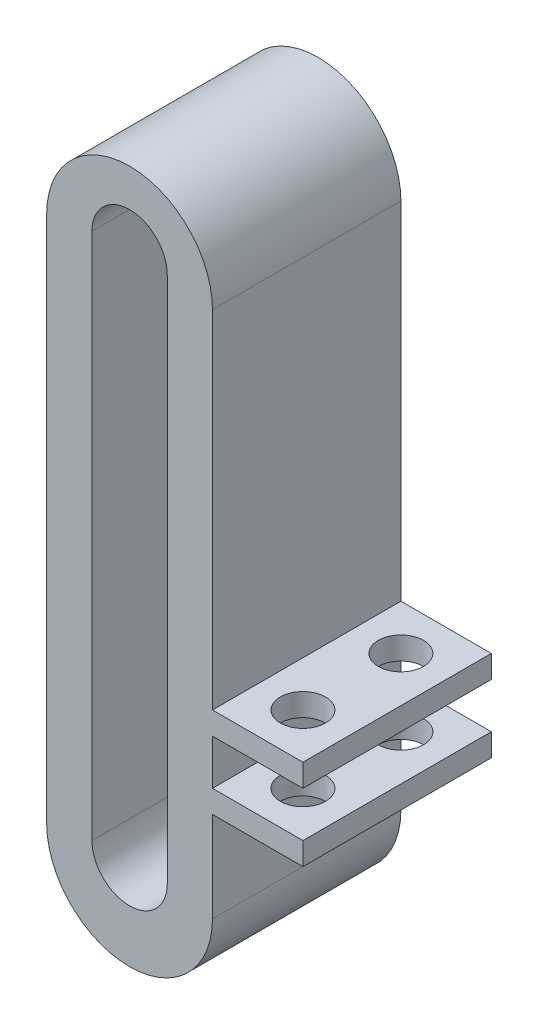
from build123d import *

# Parameters (mm, degrees)
BOSS_EXTRUDE1_DEPTH     = 12.5
SKETCH2_W               = 12.5
SKETCH2_H               = 1.5
BOSS_EXTRUDE2_DEPTH     = 6
SKETCH3_R               = 1.5
CUT_EXTRUDE1_DEPTH      = 34.000006013
CUT_EXTRUDE1_DEPTH_BACK = 13.999994598
SKETCH5_W               = 1
SKETCH5_H               = 5
CUT_EXTRUDE2_DEPTH      = 24.499994598


with BuildPart() as part:
    # Sketch1 → Boss-Extrude1 (new body)
    with BuildSketch(Plane.XY):
        with BuildLine():
            Line((5.5, 17), (5.5, -18))
            ThreePointArc((5.5, -18), (-2.701e-06, -23.499994598), (-5.5, -17.999994598))
            Line((-5.5, -17.999994598), (-5.5, 17.000006013))
            ThreePointArc((-5.5, 17.000006013), (3.006e-06, 22.500006013), (5.5, 17))
        make_face()
        with BuildLine():
            Line((2.5, 17.5), (2.5, -17.5))
            ThreePointArc((2.5, -17.5), (0, -20), (-2.5, -17.5))
            Line((-2.5, -17.5), (-2.5, 17.5))
            ThreePointArc((-2.5, 17.5), (0, 20), (2.5, 17.5))
        make_face(mode=Mode.SUBTRACT)
    extrude(amount=BOSS_EXTRUDE1_DEPTH)

    # Sketch2 → Boss-Extrude2 (add)
    with BuildSketch(Plane(origin=(5.5, 0, 0), x_dir=(0, 0, -1), z_dir=(1, 0, 0))):
        with Locations((-6.25, -11.25)):
            Rectangle(SKETCH2_W, SKETCH2_H)
        with Locations((-6.25, -6.75)):
            Rectangle(SKETCH2_W, SKETCH2_H)
    extrude(amount=BOSS_EXTRUDE2_DEPTH)

    # Sketch3 → Cut-Extrude1 (cut, two sides)
    with BuildSketch(Plane(origin=(0, -10.5, 0), x_dir=(1, 0, 0), z_dir=(0, 1, 0))) as cut_extrude1_sk:
        with Locations((8.5, -3)):
            Circle(SKETCH3_R)
        with Locations((8.5, -9.5)):
            Circle(SKETCH3_R)
    extrude(amount=CUT_EXTRUDE1_DEPTH, mode=Mode.SUBTRACT)
    extrude(cut_extrude1_sk.sketch, amount=-CUT_EXTRUDE1_DEPTH_BACK, mode=Mode.SUBTRACT)

    # Sketch5 → Cut-Extrude2 (cut, through all)
    with BuildSketch(Plane(origin=(0, 0, 0), x_dir=(1, 0, 0), z_dir=(0, 1, 0))):
        with Locations((0, -6.25)):
            Rectangle(SKETCH5_W, SKETCH5_H)
    extrude(amount=-CUT_EXTRUDE2_DEPTH, mode=Mode.SUBTRACT)


solid = part.part
